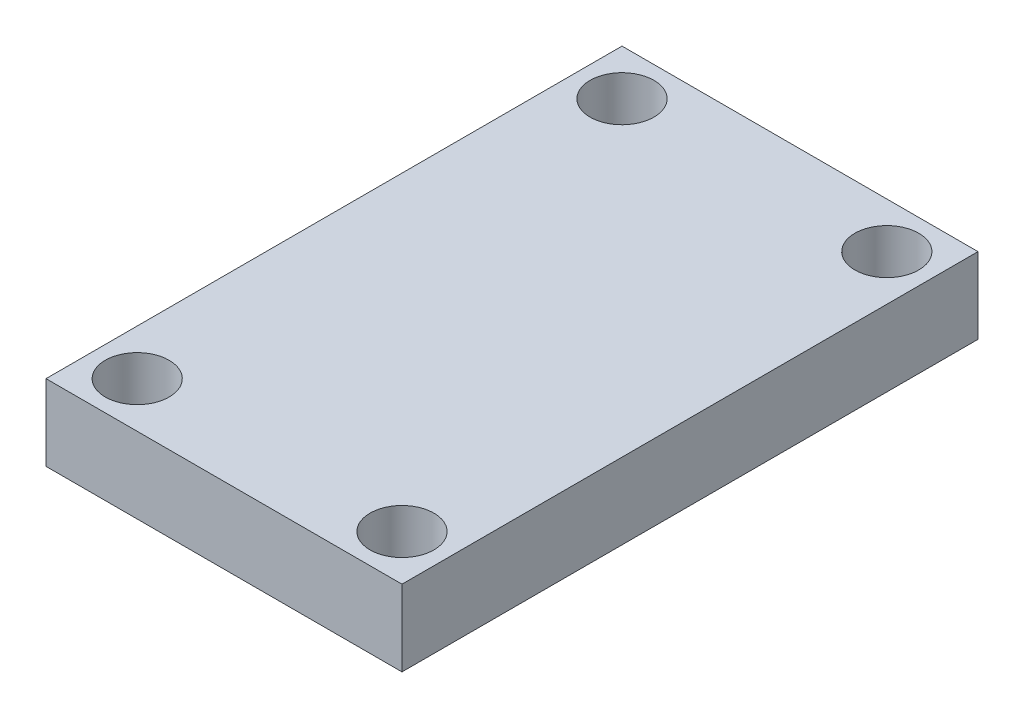
from build123d import *

# Parameters (mm, degrees)
SKETCH1_W           = 29.747622583
SKETCH1_H           = 48.133
SKETCH1_R           = 2.667
BOSS_EXTRUDE1_DEPTH = 6.35


with BuildPart() as part:
    # Sketch1 → Boss-Extrude1 (new body)
    with BuildSketch(Plane(origin=(0, 0, 0), x_dir=(1, 0, 0), z_dir=(0, 1, 0))):
        with Locations((-1.456542193, -4.720684125)):
            Rectangle(SKETCH1_W, SKETCH1_H)
        with Locations((9.607269098, 15.535815875)):
            Circle(SKETCH1_R, mode=Mode.SUBTRACT)
        with Locations((9.607269098, -24.977184125)):
            Circle(SKETCH1_R, mode=Mode.SUBTRACT)
        with Locations((-12.520353485, -24.977184125)):
            Circle(SKETCH1_R, mode=Mode.SUBTRACT)
        with Locations((-12.520353485, 15.535815875)):
            Circle(SKETCH1_R, mode=Mode.SUBTRACT)
    extrude(amount=BOSS_EXTRUDE1_DEPTH)


solid = part.part
